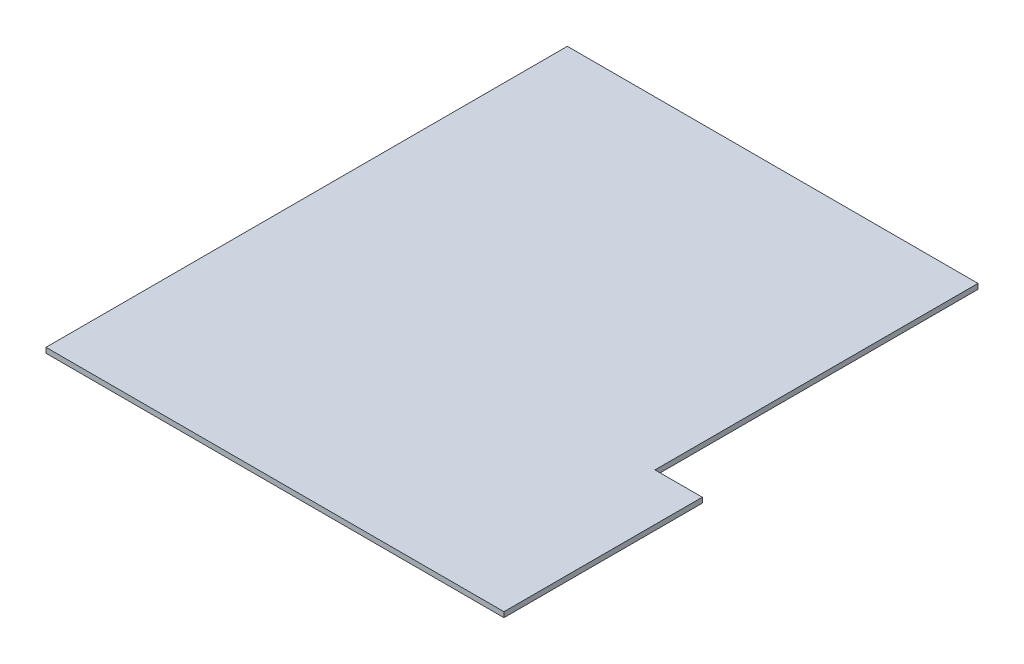
from build123d import *

# Parameters (mm, degrees)
BOSS_EXTRUDE3_DEPTH = 110


with BuildPart() as part:
    # Sketch1 → Boss-Extrude3 (new body)
    with BuildSketch(Plane(origin=(0, 0, 0), x_dir=(1, 0, 0), z_dir=(0, 1, 0))):
        Polygon((9680, 0), (9680, 4191.8), (8680, 4191.8), (8680, 11020), (0, 11020), (0, 0), align=None)
    extrude(amount=BOSS_EXTRUDE3_DEPTH)


solid = part.part
